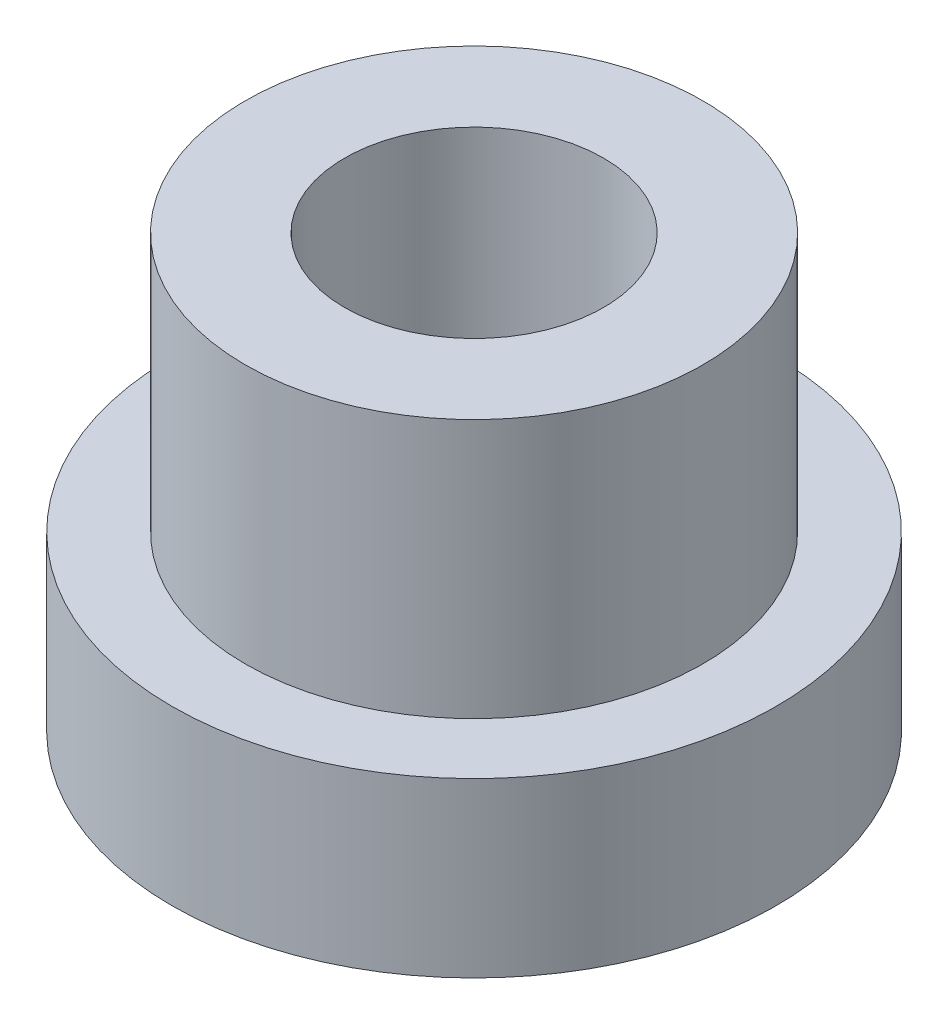
from build123d import *

# Parameters (mm, degrees)
ESBO_O1_R                = 3.5
RESSALTO_EXTRUS_O1_DEPTH = 2
ESBO_O2_R                = 2.65
RESSALTO_EXTRUS_O2_DEPTH = 3
ESBO_O3_R                = 1.5
CORTE_EXTRUS_O1_DEPTH    = 4


with BuildPart() as part:
    # Esboço1 → Ressalto-extrusão1 (new body)
    with BuildSketch(Plane(origin=(0, 0, 0), x_dir=(1, 0, 0), z_dir=(0, 1, 0))):
        Circle(ESBO_O1_R)
    extrude(amount=RESSALTO_EXTRUS_O1_DEPTH)

    # Esboço2 → Ressalto-extrusão2 (add)
    with BuildSketch(Plane(origin=(0, 2, 0), x_dir=(1, 0, 0), z_dir=(0, 1, 0))):
        Circle(ESBO_O2_R)
    extrude(amount=RESSALTO_EXTRUS_O2_DEPTH)

    # Esboço3 → Corte-extrusão1 (cut)
    with BuildSketch(Plane(origin=(0, 5, 0), x_dir=(1, 0, 0), z_dir=(0, 1, 0))):
        Circle(ESBO_O3_R)
    extrude(amount=-CORTE_EXTRUS_O1_DEPTH, mode=Mode.SUBTRACT)


solid = part.part
